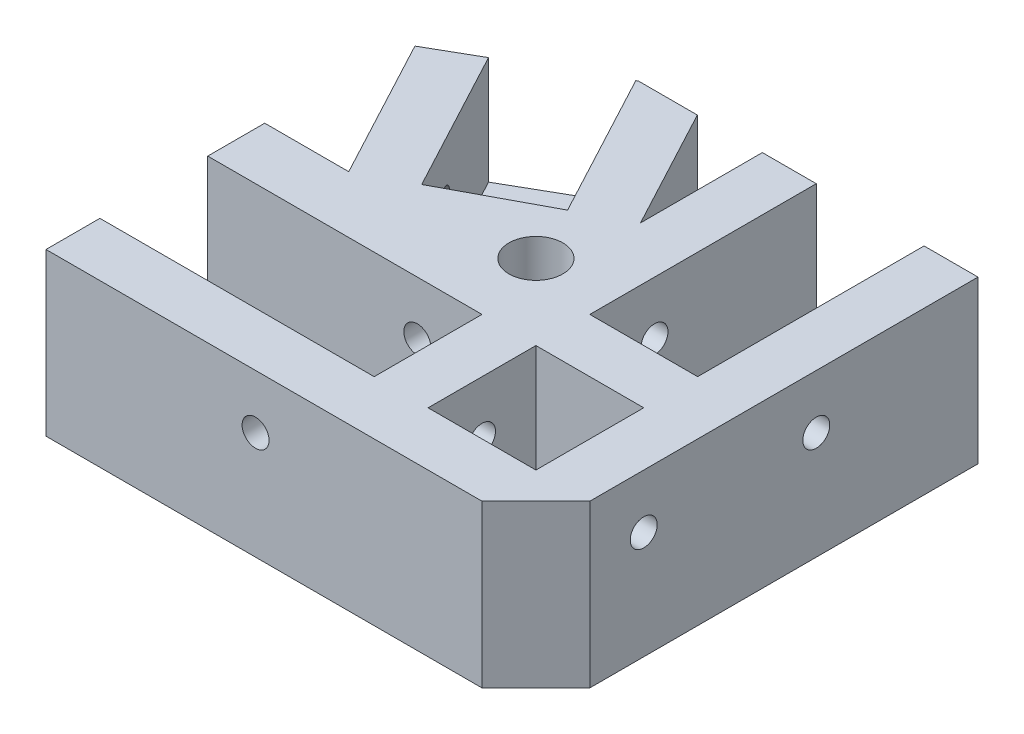
from build123d import *

# Parameters (mm, degrees)
SALIENTE_EXTRUIR1_DEPTH = 38.1
CROQUIS2_W              = 25.4
CROQUIS2_H              = 25.4
CORTAR_EXTRUIR1_DEPTH   = 25.4
CROQUIS3_W              = 64.605839452
CROQUIS3_H              = 25.4
CORTAR_EXTRUIR2_DEPTH   = 25.4
CROQUIS4_W              = 25.4
CROQUIS4_H              = 53.34
CORTAR_EXTRUIR3_DEPTH   = 25.4
CORTAR_EXTRUIR4_DEPTH   = 25.4
CORTAR_EXTRUIR5_DEPTH   = 25.4
CROQUIS7_R              = 3.175
CORTAR_EXTRUIR6_DEPTH   = 50.8
CROQUIS8_R              = 3.175
CORTAR_EXTRUIR7_DEPTH   = 50.8
CROQUIS10_R             = 3.175
CORTAR_EXTRUIR9_DEPTH   = 43.18
CROQUIS11_R             = 3.175
CORTAR_EXTRUIR10_DEPTH  = 50.8
SKETCH1_R               = 6.35
CUT_EXTRUDE1_DEPTH      = 39.1


with BuildPart() as part:
    # Croquis1 → Saliente-Extruir1 (new body)
    with BuildSketch(Plane(origin=(0, 0, 0), x_dir=(1, 0, 0), z_dir=(0, 1, 0))):
        Polygon((25.4, 78.74), (25.4, -12.7), (12.7, -25.4), (-90.005839452, -25.4), (-90.005839452, 58.42), (-54.552420926, 78.74), align=None)
    extrude(amount=SALIENTE_EXTRUIR1_DEPTH)

    # Croquis2 → Cortar-Extruir1 (cut)
    with BuildSketch(Plane(origin=(0, 38.1, 0), x_dir=(1, 0, 0), z_dir=(0, 1, 0))):
        Rectangle(CROQUIS2_W, CROQUIS2_H)
    extrude(amount=-CORTAR_EXTRUIR1_DEPTH, mode=Mode.SUBTRACT)

    # Croquis3 → Cortar-Extruir2 (cut)
    with BuildSketch(Plane(origin=(0, 38.1, 0), x_dir=(1, 0, 0), z_dir=(0, 1, 0))):
        with Locations((-57.702919726, 0)):
            Rectangle(CROQUIS3_W, CROQUIS3_H)
    extrude(amount=-CORTAR_EXTRUIR2_DEPTH, mode=Mode.SUBTRACT)

    # Croquis4 → Cortar-Extruir3 (cut)
    with BuildSketch(Plane(origin=(0, 38.1, 0), x_dir=(1, 0, 0), z_dir=(0, 1, 0))):
        with Locations((0, 52.07)):
            Rectangle(CROQUIS4_W, CROQUIS4_H)
    extrude(amount=-CORTAR_EXTRUIR3_DEPTH, mode=Mode.SUBTRACT)

    # Croquis5 → Cortar-Extruir4 (cut)
    with BuildSketch(Plane(origin=(0, 38.1, 0), x_dir=(1, 0, 0), z_dir=(0, 1, 0))):
        Polygon((-59.011096598, 32.102249098), (-36.601753481, 44.059729647), (-54.977056362, 78.496621719), (-77.024213035, 65.860372741), align=None)
    extrude(amount=-CORTAR_EXTRUIR4_DEPTH, mode=Mode.SUBTRACT)

    # Croquis6 → Cortar-Extruir5 (cut)
    with BuildSketch(Plane(origin=(0, 38.1, 0), x_dir=(1, 0, 0), z_dir=(0, 1, 0))):
        Polygon((-25.397081923, 50.038469922), (-40.712032739, 78.74), (-25.397081923, 78.74), align=None)
        Polygon((-70.215768156, 26.123508824), (-88.047791372, 59.542248253), (-90.005839452, 58.42), (-90.005839452, 26.123508824), align=None)
    extrude(amount=-CORTAR_EXTRUIR5_DEPTH, mode=Mode.SUBTRACT)

    # Croquis7 → Cortar-Extruir6 (cut)
    with BuildSketch(Plane.XY.offset(25.4)):
        with Locations((-40.64, 25.4)):
            Circle(CROQUIS7_R)
    extrude(amount=-CORTAR_EXTRUIR6_DEPTH, mode=Mode.SUBTRACT)

    # Croquis8 → Cortar-Extruir7 (cut)
    with BuildSketch(Plane(origin=(25.4, 0, 0), x_dir=(0, 0, -1), z_dir=(1, 0, 0))):
        with Locations((40.64, 25.4)):
            Circle(CROQUIS8_R)
    extrude(amount=-CORTAR_EXTRUIR7_DEPTH, mode=Mode.SUBTRACT)

    # Croquis10 → Cortar-Extruir9 (cut)
    with BuildSketch(Plane(origin=(25.4, 0, 0), x_dir=(0, 0, -1), z_dir=(1, 0, 0))):
        with Locations((0, 25.4)):
            Circle(CROQUIS10_R)
    extrude(amount=-CORTAR_EXTRUIR9_DEPTH, mode=Mode.SUBTRACT)

    # Croquis11 → Cortar-Extruir10 (cut)
    with BuildSketch(Plane(origin=(-43.804364121, 0, 23.373725379), x_dir=(0.470766951, 0, 0.882257603), z_dir=(-0.882257603, 0, 0.470766951))):
        with Locations((-69.056927347, 25.4)):
            Circle(CROQUIS11_R)
    extrude(amount=-CORTAR_EXTRUIR10_DEPTH, mode=Mode.SUBTRACT)

    # Sketch1 → Cut-Extrude1 (cut, through all)
    with BuildSketch(Plane(origin=(0, 38.1, 0), x_dir=(1, 0, 0), z_dir=(0, 1, 0))):
        with Locations((-30.48, 30.48)):
            Circle(SKETCH1_R)
    extrude(amount=-CUT_EXTRUDE1_DEPTH, mode=Mode.SUBTRACT)


solid = part.part
